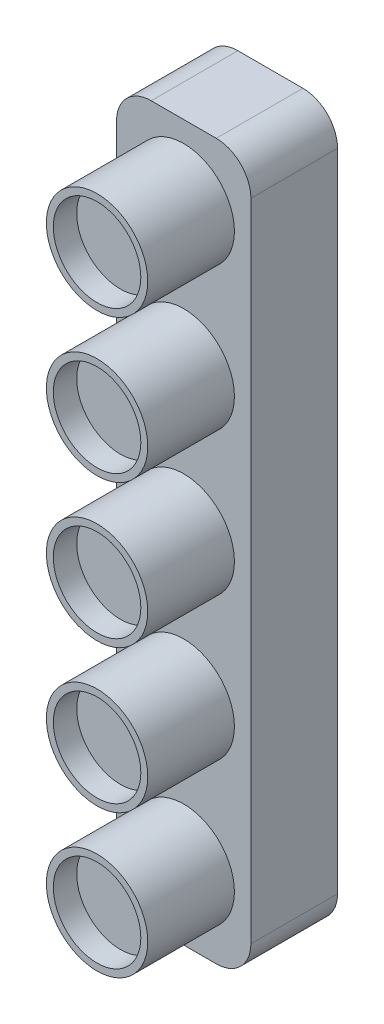
from build123d import *

# Parameters (mm, degrees)
SKETCH1_W                       = 15.5
SKETCH1_H                       = 82.5
BOSS_EXTRUDE1_DEPTH             = 20
SKETCH2_R                       = 5.85
SKETCH2_R_2                     = 5.05
CUT_EXTRUDE1_DEPTH              = 10
FILLET1_R                       = 4
SKIZZE3_R                       = 5.1
SKIZZE3_R_2                     = 5.05
AUFSATZ_LINEAR_AUSTRAGEN1_DEPTH = 7.3
SCHNITT_LINEAR_AUSTRAGEN1_DEPTH = 9


with BuildPart() as part:
    # Sketch1 → Boss-Extrude1 (new body)
    with BuildSketch(Plane.XY):
        with Locations((-157.25, 123.75)):
            Rectangle(SKETCH1_W, SKETCH1_H)
    extrude(amount=BOSS_EXTRUDE1_DEPTH)

    # Sketch2 → Cut-Extrude1 (cut)
    with BuildSketch(Plane.XY.offset(20)):
        with BuildLine():
            ThreePointArc((-163.1, 123.75), (-157.25, 129.6), (-151.4, 123.75))
            Line((-151.4, 123.75), (-149.5, 123.75))
            Line((-149.5, 123.75), (-149.5, 165))
            Line((-149.5, 165), (-165, 165))
            Line((-165, 165), (-165, 123.75))
            Line((-165, 123.75), (-163.1, 123.75))
        make_face()
        with Locations((-157.25, 140.25)):
            Circle(SKETCH2_R, mode=Mode.SUBTRACT)
        with Locations((-157.25, 156.75)):
            Circle(SKETCH2_R, mode=Mode.SUBTRACT)
        with BuildLine():
            Line((-149.5, 123.75), (-151.4, 123.75))
            ThreePointArc((-151.4, 123.75), (-157.25, 117.9), (-163.1, 123.75))
            Line((-163.1, 123.75), (-165, 123.75))
            Line((-165, 123.75), (-165, 82.5))
            Line((-165, 82.5), (-149.5, 82.5))
            Line((-149.5, 82.5), (-149.5, 123.75))
        make_face()
        with Locations((-157.25, 90.75)):
            Circle(SKETCH2_R, mode=Mode.SUBTRACT)
        with Locations((-157.25, 107.25)):
            Circle(SKETCH2_R, mode=Mode.SUBTRACT)
        with Locations((-157.25, 90.75)):
            Circle(SKETCH2_R_2)
        with Locations((-157.25, 107.25)):
            Circle(SKETCH2_R_2)
        with BuildLine():
            ThreePointArc((-162.3, 123.75), (-157.25, 118.7), (-152.2, 123.75))
            Line((-152.2, 123.75), (-162.3, 123.75))
        make_face()
        with BuildLine():
            Line((-162.3, 123.75), (-152.2, 123.75))
            ThreePointArc((-152.2, 123.75), (-157.25, 128.8), (-162.3, 123.75))
        make_face()
        with Locations((-157.25, 140.25)):
            Circle(SKETCH2_R_2)
        with Locations((-157.25, 156.75)):
            Circle(SKETCH2_R_2)
    extrude(amount=-CUT_EXTRUDE1_DEPTH, mode=Mode.SUBTRACT)

    # Fillet1
    fillet1_edges = [part.edges().sort_by_distance(p)[0] for p in [
        (-165, 165, 5),
        (-149.5, 165, 5),
        (-149.5, 82.5, 5),
        (-165, 82.5, 5),
    ]]
    fillet(fillet1_edges, radius=FILLET1_R)

    # Skizze3 → Aufsatz-Linear austragen1 (add)
    with BuildSketch(Plane.XY.offset(10)):
        with Locations((-157.25, 156.75)):
            Circle(SKIZZE3_R)
        with Locations((-157.25, 140.25)):
            Circle(SKIZZE3_R)
        with Locations((-157.25, 123.75)):
            Circle(SKIZZE3_R_2)
        with Locations((-157.25, 107.25)):
            Circle(SKIZZE3_R_2)
        with Locations((-157.25, 90.75)):
            Circle(SKIZZE3_R)
    extrude(amount=AUFSATZ_LINEAR_AUSTRAGEN1_DEPTH)

    # Skizze4 → Schnitt-Linear austragen1 (cut)
    with BuildSketch(Plane(origin=(0, 0, 0), x_dir=(-1, 0, 0), z_dir=(0, 0, -1))):
        with BuildLine():
            Line((161, 163), (153.5, 163))
            ThreePointArc((153.5, 163), (152.085786438, 162.414213562), (151.5, 161))
            Line((151.5, 161), (151.5, 86.5))
            ThreePointArc((151.5, 86.5), (152.085786438, 85.085786438), (153.5, 84.5))
            Line((153.5, 84.5), (161, 84.5))
            ThreePointArc((161, 84.5), (162.414213562, 85.085786438), (163, 86.5))
            Line((163, 86.5), (163, 161))
            ThreePointArc((163, 161), (162.414213562, 162.414213562), (161, 163))
        make_face()
    extrude(amount=-SCHNITT_LINEAR_AUSTRAGEN1_DEPTH, mode=Mode.SUBTRACT)


solid = part.part
